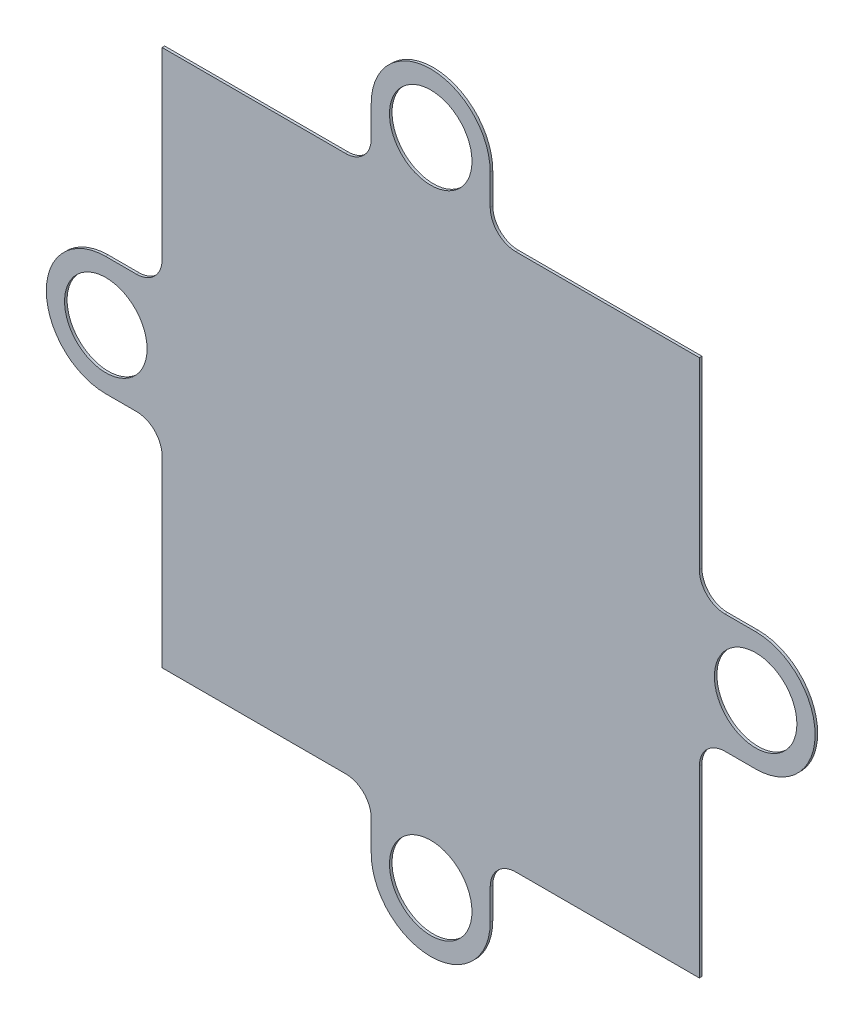
from build123d import *

# Parameters (mm, degrees)
SKETCH1_R           = 3.225
BOSS_EXTRUDE1_DEPTH = 0.2


with BuildPart() as part:
    # Sketch1 → Boss-Extrude1 (new body)
    with BuildSketch(Plane.XY):
        with BuildLine():
            ThreePointArc((4.65, 25.4), (0, 30.05), (-4.65, 25.4))
            Line((-4.65, 25.4), (-4.65, 23))
            ThreePointArc((-4.65, 23), (-5.235786438, 21.585786438), (-6.65, 21))
            Line((-6.65, 21), (-8.759132098, 21))
            Line((-8.759132098, 21), (-21, 21))
            Line((-21, 21), (-21, 7.133487824))
            Line((-21, 7.133487824), (-21, 6.65))
            ThreePointArc((-21, 6.65), (-21.585786438, 5.235786438), (-23, 4.65))
            Line((-23, 4.65), (-25.4, 4.65))
            ThreePointArc((-25.4, 4.65), (-30.05, 0), (-25.4, -4.65))
            Line((-25.4, -4.65), (-23, -4.65))
            ThreePointArc((-23, -4.65), (-21.585786438, -5.235786438), (-21, -6.65))
            Line((-21, -6.65), (-21, -8.759132098))
            Line((-21, -8.759132098), (-21, -21))
            Line((-21, -21), (-7.133487824, -21))
            Line((-7.133487824, -21), (-6.65, -21))
            ThreePointArc((-6.65, -21), (-5.235786438, -21.585786438), (-4.65, -23))
            Line((-4.65, -23), (-4.65, -25.4))
            ThreePointArc((-4.65, -25.4), (0, -30.05), (4.65, -25.4))
            Line((4.65, -25.4), (4.65, -23))
            ThreePointArc((4.65, -23), (5.235786438, -21.585786438), (6.65, -21))
            Line((6.65, -21), (8.759132098, -21))
            Line((8.759132098, -21), (21, -21))
            Line((21, -21), (21, -7.133487824))
            Line((21, -7.133487824), (21, -6.65))
            ThreePointArc((21, -6.65), (21.585786438, -5.235786438), (23, -4.65))
            Line((23, -4.65), (25.4, -4.65))
            ThreePointArc((25.4, -4.65), (30.05, 0), (25.4, 4.65))
            Line((25.4, 4.65), (23, 4.65))
            ThreePointArc((23, 4.65), (21.585786438, 5.235786438), (21, 6.65))
            Line((21, 6.65), (21, 8.759132098))
            Line((21, 8.759132098), (21, 21))
            Line((21, 21), (7.133487824, 21))
            Line((7.133487824, 21), (6.65, 21))
            ThreePointArc((6.65, 21), (5.235786438, 21.585786438), (4.65, 23))
            Line((4.65, 23), (4.65, 25.4))
        make_face()
        with Locations((0, -25.4)):
            Circle(SKETCH1_R, mode=Mode.SUBTRACT)
        with Locations((25.4, 0)):
            Circle(SKETCH1_R, mode=Mode.SUBTRACT)
        with Locations((-25.4, 0)):
            Circle(SKETCH1_R, mode=Mode.SUBTRACT)
        with Locations((0, 25.4)):
            Circle(SKETCH1_R, mode=Mode.SUBTRACT)
    extrude(amount=BOSS_EXTRUDE1_DEPTH)


solid = part.part
